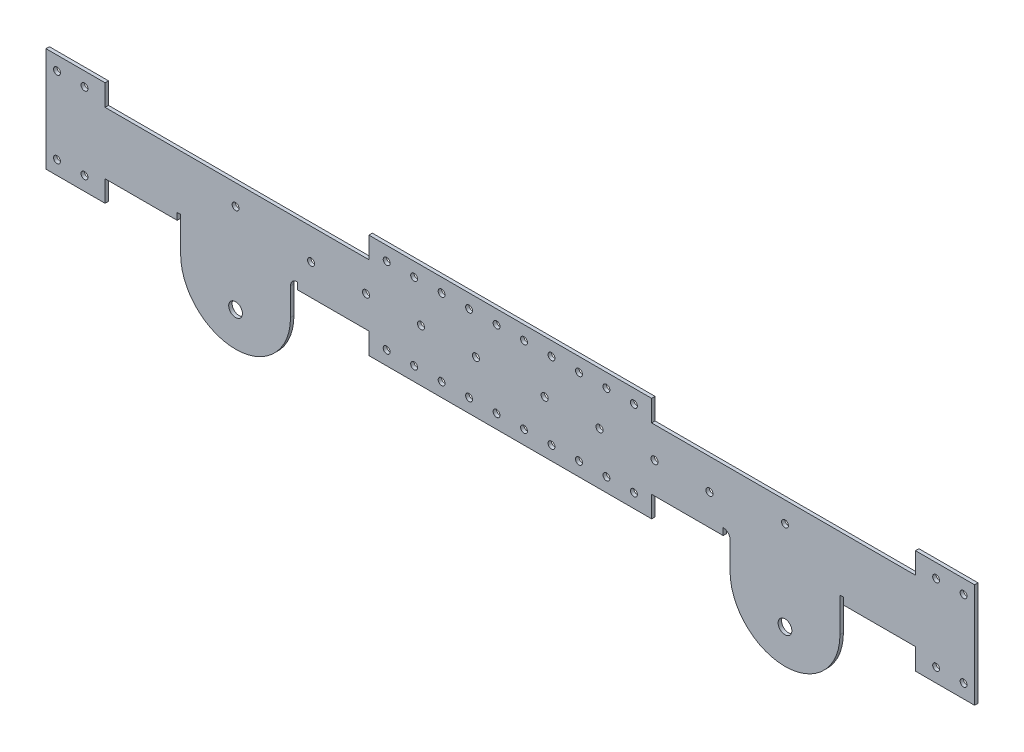
from build123d import *
from build123d.topology import SkipClean

# Parameters (mm, degrees)
SKETCH1_R            = 6.35
BOSS_EXTRUDE1_DEPTH  = 3.175
SKETCH2_W            = 596.9
SKETCH2_H            = 3.175
BOSS_EXTRUDE2_DEPTH  = 25.4
FILLET1_R            = 2.54
SKETCH3_R            = 3.2639
CUT_EXTRUDE1_DEPTH   = 25.4
SKETCH5_R            = 3.2639
CUT_EXTRUDE2_DEPTH   = 25.4
SKETCH6_W            = 31.75
SKETCH6_H            = 44.45
BOSS_EXTRUDE3_DEPTH  = 3.175
SKETCH7_W            = 31.75
SKETCH7_H            = 3.175
SKETCH7_W_2          = 381
BOSS_EXTRUDE4_DEPTH  = 25.4
FILLET2_R            = 2.54
SKETCH8_R            = 3.2639
CUT_EXTRUDE3_DEPTH   = 177.8
SKETCH9_R            = 3.2639
CUT_EXTRUDE5_DEPTH   = 432.308
BOSS_EXTRUDE6_DEPTH  = 66.675
BOSS_EXTRUDE7_START  = 66.675
BOSS_EXTRUDE7_DEPTH  = 66.675
SKETCH12_R           = 6.35
SKETCH12_R_2         = 3.2639
SKETCH12_W           = 256.6289
SKETCH12_H           = 252.715944366
CUT_EXTRUDE8_DEPTH   = 66.675
BOSS_EXTRUDE8_START  = 19.05
BOSS_EXTRUDE8_DEPTH  = 19.05
BOSS_EXTRUDE9_DEPTH  = 19.05
SKETCH16_R           = 3.2639
CUT_EXTRUDE9_DEPTH   = 133.096
SKETCH17_R           = 3.175
CUT_EXTRUDE11_DEPTH  = 5.08
SKETCH18_W           = 256.6289
SKETCH18_H           = 3.175
SKETCH18_W_2         = 838.2
BOSS_EXTRUDE10_DEPTH = 3.175
SKETCH19_W           = 107.950440108
SKETCH19_H           = 6.388661832
SKETCH19_W_2         = 107.95
SKETCH19_H_2         = 3.175
CUT_EXTRUDE12_DEPTH  = 3.175
SKETCH20_W           = 555.272296498
SKETCH20_H           = 244.428342312
SKETCH20_R           = 3.2639
SKETCH20_R_2         = 6.35
SKETCH20_R_3         = 3.175
CUT_EXTRUDE13_DEPTH  = 277.622
BOSS_EXTRUDE11_START = -3.175
SKETCH21_R           = 6.35
BOSS_EXTRUDE11_DEPTH = 3.175
SKETCH22_W           = 47.625
SKETCH22_H           = 22.225
SKETCH22_W_2         = 236.0422
BOSS_EXTRUDE12_DEPTH = 3.175
SKETCH23_W           = 47.625
SKETCH23_H           = 22.225
SKETCH23_W_2         = 236.0422
BOSS_EXTRUDE14_DEPTH = 3.175
BOSS_EXTRUDE15_DEPTH = 12.7
BOSS_EXTRUDE16_START = 12.7
BOSS_EXTRUDE16_DEPTH = 12.7
SKETCH27_R           = 3.175
CUT_EXTRUDE15_DEPTH  = 76.2
SKETCH28_W           = 22.225
SKETCH28_H           = 3.175
BOSS_EXTRUDE17_DEPTH = 12.7
SKETCH29_W           = 22.225
SKETCH29_H           = 3.175
BOSS_EXTRUDE18_DEPTH = 12.7
SKETCH30_R           = 6.321493949
BOSS_EXTRUDE19_DEPTH = 3.175
SKETCH31_R           = 6.35
CUT_EXTRUDE16_DEPTH  = 3.175
SKETCH32_W           = 28.574777667
SKETCH32_H           = 18.699670679
BOSS_EXTRUDE20_DEPTH = 3.175
CUT_EXTRUDE17_START  = -5.715
CUT_EXTRUDE17_DEPTH  = 5.715
CUT_EXTRUDE18_DEPTH  = 5.715
SKETCH35_R           = 3.175
BOSS_EXTRUDE21_DEPTH = 3.175
SKETCH36_W           = 977.185411366
SKETCH36_H           = 114.319758196
CUT_EXTRUDE19_DEPTH  = 76.2


with BuildPart() as part:
    # Sketch1 → Boss-Extrude1 (new body)
    with BuildSketch(Plane.XY):
        with BuildLine():
            Line((50.8, 0), (50.8, 25.4))
            ThreePointArc((50.8, 25.4), (52.659871939, 29.890128061), (57.15, 31.75))
            Line((57.15, 31.75), (438.15, 31.75))
            ThreePointArc((438.15, 31.75), (442.640128061, 29.890128061), (444.5, 25.4))
            Line((444.5, 25.4), (444.5, 0))
            ThreePointArc((444.5, 0), (495.3, -50.8), (546.1, 0))
            Line((546.1, 0), (546.1, 76.2))
            Line((546.1, 76.2), (-50.8, 76.2))
            Line((-50.8, 76.2), (-50.8, 0))
            ThreePointArc((-50.8, 0), (0, -50.8), (50.8, 0))
        make_face()
        Circle(SKETCH1_R, mode=Mode.SUBTRACT)
        with Locations((495.3, 0)):
            Circle(SKETCH1_R, mode=Mode.SUBTRACT)
    extrude(amount=BOSS_EXTRUDE1_DEPTH)

    # Sketch2 → Boss-Extrude2 (add)
    with BuildSketch(Plane.XY.offset(3.175)):
        with Locations((247.65, 74.6125)):
            Rectangle(SKETCH2_W, SKETCH2_H)
    extrude(amount=BOSS_EXTRUDE2_DEPTH)

    # Fillet1
    fillet1_edges = [part.edges().sort_by_distance(p)[0] for p in [
        (247.65, 73.025, 3.175),
        (247.65, 76.2, 0),
    ]]
    fillet(fillet1_edges, radius=FILLET1_R)

    # Sketch3 → Cut-Extrude1 (cut)
    with BuildSketch(Plane(origin=(0, 76.2, 0), x_dir=(1, 0, 0), z_dir=(0, 1, 0))):
        with Locations((527.05, -15.5575)):
            Circle(SKETCH3_R)
        with Locations((501.65, -15.5575)):
            Circle(SKETCH3_R)
        with Locations((476.25, -15.5575)):
            Circle(SKETCH3_R)
        with Locations((450.85, -15.5575)):
            Circle(SKETCH3_R)
        with Locations((425.45, -15.5575)):
            Circle(SKETCH3_R)
        with Locations((400.05, -15.5575)):
            Circle(SKETCH3_R)
        with Locations((374.65, -15.5575)):
            Circle(SKETCH3_R)
        with Locations((349.25, -15.5575)):
            Circle(SKETCH3_R)
        with Locations((323.85, -15.5575)):
            Circle(SKETCH3_R)
        with Locations((298.45, -15.5575)):
            Circle(SKETCH3_R)
        with Locations((273.05, -15.5575)):
            Circle(SKETCH3_R)
        with Locations((247.65, -15.5575)):
            Circle(SKETCH3_R)
        with Locations((222.25, -15.5575)):
            Circle(SKETCH3_R)
        with Locations((196.85, -15.5575)):
            Circle(SKETCH3_R)
        with Locations((171.45, -15.5575)):
            Circle(SKETCH3_R)
        with Locations((146.05, -15.5575)):
            Circle(SKETCH3_R)
        with Locations((120.65, -15.5575)):
            Circle(SKETCH3_R)
        with Locations((95.25, -15.5575)):
            Circle(SKETCH3_R)
        with Locations((69.85, -15.5575)):
            Circle(SKETCH3_R)
        with Locations((44.45, -15.5575)):
            Circle(SKETCH3_R)
        with Locations((19.05, -15.5575)):
            Circle(SKETCH3_R)
        with Locations((-6.35, -15.5575)):
            Circle(SKETCH3_R)
        with Locations((-31.75, -15.5575)):
            Circle(SKETCH3_R)
    extrude(amount=-CUT_EXTRUDE1_DEPTH, mode=Mode.SUBTRACT)

    # Sketch5 → Cut-Extrude2 (cut)
    with BuildSketch(Plane(origin=(0, 0, 0), x_dir=(-1, 0, 0), z_dir=(0, 0, -1))):
        with Locations((-425.45, 53.975)):
            Circle(SKETCH5_R)
        with Locations((-374.65, 53.975)):
            Circle(SKETCH5_R)
        with Locations((-323.85, 53.975)):
            Circle(SKETCH5_R)
        with Locations((-273.05, 53.975)):
            Circle(SKETCH5_R)
        with Locations((-222.25, 53.975)):
            Circle(SKETCH5_R)
        with Locations((-171.45, 53.975)):
            Circle(SKETCH5_R)
        with Locations((-120.65, 53.975)):
            Circle(SKETCH5_R)
        with Locations((-69.85, 53.975)):
            Circle(SKETCH5_R)
    extrude(amount=-CUT_EXTRUDE2_DEPTH, mode=Mode.SUBTRACT)

    # Sketch6 → Boss-Extrude3 (add)
    with BuildSketch(Plane.XY.offset(3.175)):
        with Locations((-66.675, 53.975)):
            Rectangle(SKETCH6_W, SKETCH6_H)
        with Locations((561.975, 53.975)):
            Rectangle(SKETCH6_W, SKETCH6_H)
    extrude(amount=-BOSS_EXTRUDE3_DEPTH)

    # Sketch7 → Boss-Extrude4 (add)
    with BuildSketch(Plane.XY.offset(3.175)):
        with Locations((-66.675, 74.6125)):
            Rectangle(SKETCH7_W, SKETCH7_H)
        with Locations((-66.675, 33.3375)):
            Rectangle(SKETCH7_W, SKETCH7_H)
        with Locations((561.975, 74.6125)):
            Rectangle(SKETCH7_W, SKETCH7_H)
        with Locations((561.975, 33.3375)):
            Rectangle(SKETCH7_W, SKETCH7_H)
        with Locations((247.65, 33.3375)):
            Rectangle(SKETCH7_W_2, SKETCH7_H)
    extrude(amount=BOSS_EXTRUDE4_DEPTH)

    # Fillet2
    fillet2_edges = [part.edges().sort_by_distance(p)[0] for p in [
        (-50.8, 15.875, 0),
        (0, -50.8, 0),
        (50.8, 12.7, 0),
        (52.659871939, 29.890128061, 0),
        (546.1, 15.875, 0),
        (495.3, -50.8, 0),
        (444.5, 12.7, 0),
        (442.640128061, 29.890128061, 0),
        (-66.675, 34.925, 3.175),
        (-66.675, 31.75, 0),
        (247.65, 31.75, 0),
        (247.65, 34.925, 3.175),
        (561.975, 34.925, 3.175),
        (561.975, 31.75, 0),
        (561.975, 76.2, 0),
        (-66.675, 76.2, 0),
    ]]
    fillet(fillet2_edges, radius=FILLET2_R)

    # Sketch8 → Cut-Extrude3 (cut)
    with BuildSketch(Plane(origin=(0, 76.2, 0), x_dir=(1, 0, 0), z_dir=(0, 1, 0))):
        with Locations((-31.75, -15.5575)):
            Circle(SKETCH8_R)
        with Locations((-57.15, -15.5575)):
            Circle(SKETCH8_R)
        with Locations((-6.35, -15.5575)):
            Circle(SKETCH8_R)
        with Locations((19.05, -15.5575)):
            Circle(SKETCH8_R)
        with Locations((44.45, -15.5575)):
            Circle(SKETCH8_R)
        with Locations((69.85, -15.5575)):
            Circle(SKETCH8_R)
        with Locations((95.25, -15.5575)):
            Circle(SKETCH8_R)
        with Locations((120.65, -15.5575)):
            Circle(SKETCH8_R)
        with Locations((146.05, -15.5575)):
            Circle(SKETCH8_R)
        with Locations((171.45, -15.5575)):
            Circle(SKETCH8_R)
        with Locations((196.85, -15.5575)):
            Circle(SKETCH8_R)
        with Locations((222.25, -15.5575)):
            Circle(SKETCH8_R)
        with Locations((247.65, -15.5575)):
            Circle(SKETCH8_R)
        with Locations((273.05, -15.5575)):
            Circle(SKETCH8_R)
        with Locations((298.45, -15.5575)):
            Circle(SKETCH8_R)
        with Locations((323.85, -15.5575)):
            Circle(SKETCH8_R)
        with Locations((349.25, -15.5575)):
            Circle(SKETCH8_R)
        with Locations((374.65, -15.5575)):
            Circle(SKETCH8_R)
        with Locations((400.05, -15.5575)):
            Circle(SKETCH8_R)
        with Locations((425.45, -15.5575)):
            Circle(SKETCH8_R)
        with Locations((450.85, -15.5575)):
            Circle(SKETCH8_R)
        with Locations((476.25, -15.5575)):
            Circle(SKETCH8_R)
        with Locations((501.65, -15.5575)):
            Circle(SKETCH8_R)
        with Locations((527.05, -15.5575)):
            Circle(SKETCH8_R)
        with Locations((552.45, -15.5575)):
            Circle(SKETCH8_R)
    extrude(amount=-CUT_EXTRUDE3_DEPTH, mode=Mode.SUBTRACT)

    # Sketch9 → Cut-Extrude5 (cut)
    with BuildSketch(Plane(origin=(0, 76.2, 0), x_dir=(1, 0, 0), z_dir=(0, 1, 0))):
        with BuildLine():
            Line((298.45, -18.8214), (298.45, -28.575))
            Line((298.45, -28.575), (746.392900795, -28.575))
            Line((746.392900795, -28.575), (746.392900795, 89.004110939))
            Line((746.392900795, 89.004110939), (298.45, 89.004110939))
            Line((298.45, 89.004110939), (298.45, -12.2936))
            ThreePointArc((298.45, -12.2936), (301.7139, -15.5575), (298.45, -18.8214))
        make_face()
        with Locations((323.85, -15.5575)):
            Circle(SKETCH9_R, mode=Mode.SUBTRACT)
        with Locations((349.25, -15.5575)):
            Circle(SKETCH9_R, mode=Mode.SUBTRACT)
        with Locations((374.65, -15.5575)):
            Circle(SKETCH9_R, mode=Mode.SUBTRACT)
        with Locations((400.05, -15.5575)):
            Circle(SKETCH9_R, mode=Mode.SUBTRACT)
        with Locations((425.45, -15.5575)):
            Circle(SKETCH9_R, mode=Mode.SUBTRACT)
        with Locations((450.85, -15.5575)):
            Circle(SKETCH9_R, mode=Mode.SUBTRACT)
        with Locations((476.25, -15.5575)):
            Circle(SKETCH9_R, mode=Mode.SUBTRACT)
        with Locations((501.65, -15.5575)):
            Circle(SKETCH9_R, mode=Mode.SUBTRACT)
        with Locations((527.05, -15.5575)):
            Circle(SKETCH9_R, mode=Mode.SUBTRACT)
        with Locations((552.45, -15.5575)):
            Circle(SKETCH9_R, mode=Mode.SUBTRACT)
    extrude(amount=-CUT_EXTRUDE5_DEPTH, mode=Mode.SUBTRACT)

    # Mirror4: part across plane


with BuildPart() as part_1:
    with SkipClean():  # the faces are left unmerged after this step: merging them gives an invalid solid
        add(part.part)
        add(part.part.mirror(Plane(origin=(298.45, -356.108, 0), x_dir=(0, 0, 1), z_dir=(1, 0, 0))))

    # Sketch10 → Boss-Extrude6 (add)
    with SkipClean():  # the faces are left unmerged after this step: merging them gives an invalid solid
        with BuildSketch(Plane.ZY.offset(82.55)):
            with BuildLine():
                Line((0, 73.66), (0, 34.29))
                ThreePointArc((0, 34.29), (0.743948776, 32.493948776), (2.54, 31.75))
                Line((2.54, 31.75), (28.575, 31.75))
                Line((28.575, 31.75), (28.575, 34.925))
                Line((28.575, 34.925), (5.715, 34.925))
                ThreePointArc((5.715, 34.925), (3.918948776, 35.668948776), (3.175, 37.465))
                Line((3.175, 37.465), (3.175, 73.025))
                Line((3.175, 73.025), (28.575, 73.025))
                Line((28.575, 73.025), (28.575, 76.2))
                Line((28.575, 76.2), (2.54, 76.2))
                ThreePointArc((2.54, 76.2), (0.743948776, 75.456051224), (0, 73.66))
            make_face()
        extrude(amount=BOSS_EXTRUDE6_DEPTH)

    # Sketch11 → Boss-Extrude7 (add)
    with SkipClean():  # the faces are left unmerged after this step: merging them gives an invalid solid
        with BuildSketch(Plane(origin=(679.45, 0, 0), x_dir=(0, 0, -1), z_dir=(1, 0, 0)).offset(BOSS_EXTRUDE7_START)):
            with BuildLine():
                Line((0, 34.29), (0, 73.66))
                ThreePointArc((0, 73.66), (-0.743948776, 75.456051224), (-2.54, 76.2))
                Line((-2.54, 76.2), (-28.575, 76.2))
                Line((-28.575, 76.2), (-28.575, 73.025))
                Line((-28.575, 73.025), (-3.175, 73.025))
                Line((-3.175, 73.025), (-3.175, 37.465))
                ThreePointArc((-3.175, 37.465), (-3.918948776, 35.668948776), (-5.715, 34.925))
                Line((-5.715, 34.925), (-28.575, 34.925))
                Line((-28.575, 34.925), (-28.575, 31.75))
                Line((-28.575, 31.75), (-2.54, 31.75))
                ThreePointArc((-2.54, 31.75), (-0.743948776, 32.493948776), (0, 34.29))
            make_face()
        extrude(amount=-BOSS_EXTRUDE7_DEPTH)

    # Sketch12 → Cut-Extrude8 (cut)
    # profile 1 of 2: a face of its own
    with SkipClean():  # the faces are left unmerged after this step: merging them gives an invalid solid
        with BuildSketch(Plane.XY.offset(3.175)):
            with BuildLine():
                Line((135.9789, 114.3), (-120.65, 114.3))
                Line((-120.65, 114.3), (-120.65, -7.986269461))
                Line((-120.65, -7.986269461), (-114.3, -7.986269461))
                Line((-114.3, -7.986269461), (-114.3, 0))
                ThreePointArc((-114.3, 0), (0, -114.3), (114.3, 0))
                Line((114.3, 0), (114.3, -15.458780647))
                Line((114.3, -15.458780647), (135.9789, -15.458780647))
                Line((135.9789, -15.458780647), (135.9789, 114.3))
            make_face()
            Circle(SKETCH12_R, mode=Mode.SUBTRACT)
            with Locations((69.85, 53.975)):
                Circle(SKETCH12_R_2, mode=Mode.SUBTRACT)
            with Locations((120.65, 53.975)):
                Circle(SKETCH12_R_2, mode=Mode.SUBTRACT)
        # profile 2 of 2: a face of its own
        with BuildSketch(Plane.XY.offset(3.175)):
            with Locations((589.23555, 8.748218221)):
                Rectangle(SKETCH12_W, SKETCH12_H)
            with Locations((596.9, 0)):
                Circle(SKETCH12_R, mode=Mode.SUBTRACT)
            with Locations((476.25, 53.975)):
                Circle(SKETCH12_R_2, mode=Mode.SUBTRACT)
            with Locations((527.05, 53.975)):
                Circle(SKETCH12_R_2, mode=Mode.SUBTRACT)
        extrude(amount=CUT_EXTRUDE8_DEPTH, mode=Mode.SUBTRACT)

    # Sketch14 → Boss-Extrude8 (add)
    with SkipClean():  # the faces are left unmerged after this step: merging them gives an invalid solid
        with BuildSketch(Plane(origin=(746.125, 0, 0), x_dir=(0, 0, -1), z_dir=(1, 0, 0)).offset(BOSS_EXTRUDE8_START)):
            with BuildLine():
                Line((0, 34.29), (0, 73.66))
                ThreePointArc((0, 73.66), (-0.743948776, 75.456051224), (-2.54, 76.2))
                Line((-2.54, 76.2), (-28.575, 76.2))
                Line((-28.575, 76.2), (-28.575, 73.025))
                Line((-28.575, 73.025), (-3.175, 73.025))
                Line((-3.175, 73.025), (-3.175, 37.465))
                ThreePointArc((-3.175, 37.465), (-3.918948776, 35.668948776), (-5.715, 34.925))
                Line((-5.715, 34.925), (-28.575, 34.925))
                Line((-28.575, 34.925), (-28.575, 31.75))
                Line((-28.575, 31.75), (-2.54, 31.75))
                ThreePointArc((-2.54, 31.75), (-0.743948776, 32.493948776), (0, 34.29))
            make_face()
        extrude(amount=-BOSS_EXTRUDE8_DEPTH)

    # Sketch15 → Boss-Extrude9 (add)
    with SkipClean():  # the faces are left unmerged after this step: merging them gives an invalid solid
        with BuildSketch(Plane.ZY.offset(149.225)):
            with BuildLine():
                Line((0, 73.66), (0, 34.29))
                ThreePointArc((0, 34.29), (0.743948776, 32.493948776), (2.54, 31.75))
                Line((2.54, 31.75), (28.575, 31.75))
                Line((28.575, 31.75), (28.575, 34.925))
                Line((28.575, 34.925), (5.715, 34.925))
                ThreePointArc((5.715, 34.925), (3.918948776, 35.668948776), (3.175, 37.465))
                Line((3.175, 37.465), (3.175, 73.025))
                Line((3.175, 73.025), (28.575, 73.025))
                Line((28.575, 73.025), (28.575, 76.2))
                Line((28.575, 76.2), (2.54, 76.2))
                ThreePointArc((2.54, 76.2), (0.743948776, 75.456051224), (0, 73.66))
            make_face()
        extrude(amount=BOSS_EXTRUDE9_DEPTH)

    # Sketch16 → Cut-Extrude9 (cut)
    with SkipClean():  # the faces are left unmerged after this step: merging them gives an invalid solid
        with BuildSketch(Plane(origin=(0, 76.2, 0), x_dir=(1, 0, 0), z_dir=(0, 1, 0))):
            with Locations((146.05, -15.5575)):
                Circle(SKETCH16_R)
            with Locations((171.45, -15.5575)):
                Circle(SKETCH16_R)
            with Locations((196.85, -15.5575)):
                Circle(SKETCH16_R)
            with Locations((222.25, -15.5575)):
                Circle(SKETCH16_R)
            with Locations((247.65, -15.5575)):
                Circle(SKETCH16_R)
            with Locations((273.05, -15.5575)):
                Circle(SKETCH16_R)
            with Locations((298.45, -15.5575)):
                Circle(SKETCH16_R)
            with Locations((323.85, -15.5575)):
                Circle(SKETCH16_R)
            with Locations((349.25, -15.5575)):
                Circle(SKETCH16_R)
            with Locations((374.65, -15.5575)):
                Circle(SKETCH16_R)
            with Locations((400.05, -15.5575)):
                Circle(SKETCH16_R)
            with Locations((425.45, -15.5575)):
                Circle(SKETCH16_R)
            with Locations((450.85, -15.5575)):
                Circle(SKETCH16_R)
            with Locations((476.25, -15.5575)):
                Circle(SKETCH16_R)
            with Locations((501.65, -15.5575)):
                Circle(SKETCH16_R)
            with Locations((527.05, -15.5575)):
                Circle(SKETCH16_R)
            with Locations((552.45, -15.5575)):
                Circle(SKETCH16_R)
            with Locations((577.85, -15.5575)):
                Circle(SKETCH16_R)
            with Locations((603.25, -15.5575)):
                Circle(SKETCH16_R)
            with Locations((628.65, -15.5575)):
                Circle(SKETCH16_R)
            with Locations((654.05, -15.5575)):
                Circle(SKETCH16_R)
            with Locations((679.45, -15.5575)):
                Circle(SKETCH16_R)
            with Locations((704.85, -15.5575)):
                Circle(SKETCH16_R)
            with Locations((730.25, -15.5575)):
                Circle(SKETCH16_R)
            with Locations((755.65, -15.5575)):
                Circle(SKETCH16_R)
            with Locations((120.65, -15.5575)):
                Circle(SKETCH16_R)
            with Locations((95.25, -15.5575)):
                Circle(SKETCH16_R)
            with Locations((69.85, -15.5575)):
                Circle(SKETCH16_R)
            with Locations((44.45, -15.5575)):
                Circle(SKETCH16_R)
            with Locations((19.05, -15.5575)):
                Circle(SKETCH16_R)
            with Locations((-6.35, -15.5575)):
                Circle(SKETCH16_R)
            with Locations((-31.75, -15.5575)):
                Circle(SKETCH16_R)
            with Locations((-57.15, -15.5575)):
                Circle(SKETCH16_R)
            with Locations((-82.55, -15.5575)):
                Circle(SKETCH16_R)
            with Locations((-107.95, -15.5575)):
                Circle(SKETCH16_R)
            with Locations((-133.35, -15.5575)):
                Circle(SKETCH16_R)
            with Locations((-158.75, -15.5575)):
                Circle(SKETCH16_R)
        extrude(amount=-CUT_EXTRUDE9_DEPTH, mode=Mode.SUBTRACT)

    # Sketch17 → Cut-Extrude11 (cut)
    with SkipClean():  # the faces are left unmerged after this step: merging them gives an invalid solid
        with BuildSketch(Plane(origin=(0, 0, 0), x_dir=(-1, 0, 0), z_dir=(0, 0, -1))):
            with Locations((0, 63.5)):
                Circle(SKETCH17_R)
            with Locations((-596.9, 63.5)):
                Circle(SKETCH17_R)
        extrude(amount=-CUT_EXTRUDE11_DEPTH, mode=Mode.SUBTRACT)

    # Sketch18 → Boss-Extrude10 (add)
    with SkipClean():  # the faces are left unmerged after this step: merging them gives an invalid solid
        with BuildSketch(Plane.XY.offset(3.175)):
            with Locations((7.66445, 74.6125)):
                Rectangle(SKETCH18_W, SKETCH18_H)
            with Locations((589.23555, 74.6125)):
                Rectangle(SKETCH18_W, SKETCH18_H)
            with Locations((298.45, 33.3375)):
                Rectangle(SKETCH18_W_2, SKETCH18_H)
        extrude(amount=BOSS_EXTRUDE10_DEPTH)

    # Sketch19 → Cut-Extrude12 (cut)
    with SkipClean():  # the faces are left unmerged after this step: merging them gives an invalid solid
        with BuildSketch(Plane.XY.offset(3.175)):
            with Locations((3.175220054, 34.944330916)):
                Rectangle(SKETCH19_W, SKETCH19_H)
            with Locations((593.725, 33.3375)):
                Rectangle(SKETCH19_W_2, SKETCH19_H_2)
        extrude(amount=CUT_EXTRUDE12_DEPTH, mode=Mode.SUBTRACT)

    # Sketch20 → Cut-Extrude13 (cut)
    with BuildSketch(Plane(origin=(0, 0, 0), x_dir=(-1, 0, 0), z_dir=(0, 0, -1))):
        with Locations((-65.263851751, 61.916295681)):
            Rectangle(SKETCH20_W, SKETCH20_H)
        with Locations((-323.85, 53.975)):
            Circle(SKETCH20_R, mode=Mode.SUBTRACT)
        with Locations((-273.05, 53.975)):
            Circle(SKETCH20_R, mode=Mode.SUBTRACT)
        with Locations((-222.25, 53.975)):
            Circle(SKETCH20_R, mode=Mode.SUBTRACT)
        with Locations((-171.45, 53.975)):
            Circle(SKETCH20_R, mode=Mode.SUBTRACT)
        with Locations((-120.65, 53.975)):
            Circle(SKETCH20_R, mode=Mode.SUBTRACT)
        with Locations((-69.85, 53.975)):
            Circle(SKETCH20_R, mode=Mode.SUBTRACT)
        Circle(SKETCH20_R_2, mode=Mode.SUBTRACT)
        with Locations((0, 63.5)):
            Circle(SKETCH20_R_3, mode=Mode.SUBTRACT)
    extrude(amount=-CUT_EXTRUDE13_DEPTH, mode=Mode.SUBTRACT)

    # Sketch21 → Boss-Extrude11 (add)
    with BuildSketch(Plane.XY.offset(3.175).offset(BOSS_EXTRUDE11_START)):
        with BuildLine():
            Line((546.1, 0), (546.1, 25.4))
            ThreePointArc((546.1, 25.4), (544.240128061, 29.890128061), (539.75, 31.75))
            Line((539.75, 31.75), (539.75, 34.925))
            Line((539.75, 34.925), (647.7, 34.925))
            Line((647.7, 34.925), (647.7, 31.75))
            Line((647.7, 31.75), (647.7, 0))
            ThreePointArc((647.7, 0), (596.9, -50.8), (546.1, 0))
        make_face()
        with Locations((596.9, 0)):
            Circle(SKETCH21_R, mode=Mode.SUBTRACT)
    extrude(amount=BOSS_EXTRUDE11_DEPTH)

    # Mirror5: part across plane


with BuildPart() as part_2:
    add(part_1.part)
    add(part_1.part.mirror(Plane(origin=(342.9, 0, 277.622), x_dir=(0, 0, 1), z_dir=(1, 0, 0))))

    # Sketch22 → Boss-Extrude12 (add)
    with BuildSketch(Plane(origin=(0, 76.2, 0), x_dir=(1, 0, 0), z_dir=(0, 1, 0))):
        with Locations((741.3625, -17.4625)):
            Rectangle(SKETCH22_W, SKETCH22_H)
        with Locations((342.9, -17.4625)):
            Rectangle(SKETCH22_W_2, SKETCH22_H)
        with Locations((-55.5625, -17.4625)):
            Rectangle(SKETCH22_W, SKETCH22_H)
    extrude(amount=-BOSS_EXTRUDE12_DEPTH)

    # Sketch23 → Boss-Extrude14 (add)
    with BuildSketch(Plane.XZ.offset(-31.75)):
        with Locations((-55.5625, 17.4625)):
            Rectangle(SKETCH23_W, SKETCH23_H)
        with Locations((342.9, 17.4625)):
            Rectangle(SKETCH23_W_2, SKETCH23_H)
        with Locations((741.3625, 17.4625)):
            Rectangle(SKETCH23_W, SKETCH23_H)
    extrude(amount=-BOSS_EXTRUDE14_DEPTH)

    # Sketch25 → Boss-Extrude15 (add)
    with BuildSketch(Plane.ZY.offset(79.375)):
        with BuildLine():
            Line((2.54, 31.75), (28.575, 31.75))
            Line((28.575, 31.75), (28.575, 34.925))
            Line((28.575, 34.925), (5.715, 34.925))
            ThreePointArc((5.715, 34.925), (3.918948776, 35.668948776), (3.175, 37.465))
            Line((3.175, 37.465), (3.175, 73.025))
            Line((3.175, 73.025), (28.575, 73.025))
            Line((28.575, 73.025), (28.575, 76.2))
            Line((28.575, 76.2), (2.54, 76.2))
            ThreePointArc((2.54, 76.2), (0.743948776, 75.456051224), (0, 73.66))
            Line((0, 73.66), (0, 34.29))
            ThreePointArc((0, 34.29), (0.743948776, 32.493948776), (2.54, 31.75))
        make_face()
    extrude(amount=BOSS_EXTRUDE15_DEPTH)

    # Sketch26 → Boss-Extrude16 (add)
    with BuildSketch(Plane(origin=(765.175, 0, 0), x_dir=(0, 0, -1), z_dir=(1, 0, 0)).offset(BOSS_EXTRUDE16_START)):
        with BuildLine():
            Line((-5.715, 34.925), (-28.575, 34.925))
            Line((-28.575, 34.925), (-28.575, 31.75))
            Line((-28.575, 31.75), (-2.54, 31.75))
            ThreePointArc((-2.54, 31.75), (-0.743948776, 32.493948776), (0, 34.29))
            Line((0, 34.29), (0, 73.66))
            ThreePointArc((0, 73.66), (-0.743948776, 75.456051224), (-2.54, 76.2))
            Line((-2.54, 76.2), (-28.575, 76.2))
            Line((-28.575, 76.2), (-28.575, 73.025))
            Line((-28.575, 73.025), (-3.175, 73.025))
            Line((-3.175, 73.025), (-3.175, 37.465))
            ThreePointArc((-3.175, 37.465), (-3.918948776, 35.668948776), (-5.715, 34.925))
        make_face()
    extrude(amount=-BOSS_EXTRUDE16_DEPTH)

    # Sketch27 → Cut-Extrude15 (cut)
    with BuildSketch(Plane(origin=(0, 76.2, 0), x_dir=(1, 0, 0), z_dir=(0, 1, 0))):
        with Locations((762, -15.788044632)):
            Circle(SKETCH27_R)
        with Locations((736.6, -15.788044632)):
            Circle(SKETCH27_R)
        with Locations((711.2, -15.788044632)):
            Circle(SKETCH27_R)
        with Locations((685.8, -15.788044632)):
            Circle(SKETCH27_R)
        with Locations((660.4, -15.788044632)):
            Circle(SKETCH27_R)
        with Locations((635, -15.788044632)):
            Circle(SKETCH27_R)
        with Locations((609.6, -15.788044632)):
            Circle(SKETCH27_R)
        with Locations((584.2, -15.788044632)):
            Circle(SKETCH27_R)
        with Locations((558.8, -15.788044632)):
            Circle(SKETCH27_R)
        with Locations((533.4, -15.788044632)):
            Circle(SKETCH27_R)
        with Locations((508, -15.788044632)):
            Circle(SKETCH27_R)
        with Locations((482.6, -15.788044632)):
            Circle(SKETCH27_R)
        with Locations((457.2, -15.788044632)):
            Circle(SKETCH27_R)
        with Locations((431.8, -15.788044632)):
            Circle(SKETCH27_R)
        with Locations((406.4, -15.788044632)):
            Circle(SKETCH27_R)
        with Locations((381, -15.788044632)):
            Circle(SKETCH27_R)
        with Locations((355.6, -15.788044632)):
            Circle(SKETCH27_R)
        with Locations((330.2, -15.788044632)):
            Circle(SKETCH27_R)
        with Locations((304.8, -15.788044632)):
            Circle(SKETCH27_R)
        with Locations((279.4, -15.788044632)):
            Circle(SKETCH27_R)
        with Locations((254, -15.788044632)):
            Circle(SKETCH27_R)
        with Locations((228.6, -15.788044632)):
            Circle(SKETCH27_R)
        with Locations((203.2, -15.788044632)):
            Circle(SKETCH27_R)
        with Locations((177.8, -15.788044632)):
            Circle(SKETCH27_R)
        with Locations((152.4, -15.788044632)):
            Circle(SKETCH27_R)
        with Locations((127, -15.788044632)):
            Circle(SKETCH27_R)
        with Locations((101.6, -15.788044632)):
            Circle(SKETCH27_R)
        with Locations((76.2, -15.788044632)):
            Circle(SKETCH27_R)
        with Locations((50.8, -15.788044632)):
            Circle(SKETCH27_R)
        with Locations((25.4, -15.788044632)):
            Circle(SKETCH27_R)
        with Locations((0, -15.788044632)):
            Circle(SKETCH27_R)
        with Locations((-25.4, -15.788044632)):
            Circle(SKETCH27_R)
        with Locations((-50.8, -15.788044632)):
            Circle(SKETCH27_R)
        with Locations((-76.2, -15.788044632)):
            Circle(SKETCH27_R)
    extrude(amount=-CUT_EXTRUDE15_DEPTH, mode=Mode.SUBTRACT)

    # Sketch28 → Boss-Extrude17 (add)
    with BuildSketch(Plane.ZY.offset(-224.8789)):
        with Locations((17.4625, 74.6125)):
            Rectangle(SKETCH28_W, SKETCH28_H)
        with Locations((17.4625, 33.3375)):
            Rectangle(SKETCH28_W, SKETCH28_H)
    extrude(amount=BOSS_EXTRUDE17_DEPTH)

    # Sketch29 → Boss-Extrude18 (add)
    with BuildSketch(Plane(origin=(460.9211, 0, 0), x_dir=(0, 0, -1), z_dir=(1, 0, 0))):
        with Locations((-17.4625, 74.6125)):
            Rectangle(SKETCH29_W, SKETCH29_H)
        with Locations((-17.4625, 33.3375)):
            Rectangle(SKETCH29_W, SKETCH29_H)
    extrude(amount=BOSS_EXTRUDE18_DEPTH)

    # Sketch30 → Boss-Extrude19 (add)
    with BuildSketch(Plane.XY.offset(3.175)):
        with Locations((87.64816817, -19.05)):
            Circle(SKETCH30_R)
        Polygon((71.867948908, 15.024467729), (76.689488805, -7.576500536), (114.056423003, -16.014195355), (104.111996966, 17.133891434), align=None)
    extrude(amount=-BOSS_EXTRUDE19_DEPTH)

    # Sketch31 → Cut-Extrude16 (cut)
    with BuildSketch(Plane.XY.offset(3.175)):
        with Locations((88.9, -19.05)):
            Circle(SKETCH31_R)
        with Locations((596.9, -19.05)):
            Circle(SKETCH31_R)
    extrude(amount=-CUT_EXTRUDE16_DEPTH, mode=Mode.SUBTRACT)

    # Sketch32 → Boss-Extrude20 (add)
    with BuildSketch(Plane.XY.offset(3.175)):
        with Locations((601.058442049, 1.748623875)):
            Rectangle(SKETCH32_W, SKETCH32_H)
    extrude(amount=-BOSS_EXTRUDE20_DEPTH)

    # Sketch33 → Cut-Extrude17 (cut)
    with BuildSketch(Plane.ZY.offset(92.075).offset(CUT_EXTRUDE17_START)):
        with BuildLine():
            Line((2.54, 31.75), (28.575, 31.75))
            Line((28.575, 31.75), (28.575, 34.925))
            Line((28.575, 34.925), (5.715, 34.925))
            ThreePointArc((5.715, 34.925), (3.918948776, 35.668948776), (3.175, 37.465))
            Line((3.175, 37.465), (3.175, 73.025))
            Line((3.175, 73.025), (28.575, 73.025))
            Line((28.575, 73.025), (28.575, 76.2))
            Line((28.575, 76.2), (2.54, 76.2))
            ThreePointArc((2.54, 76.2), (0.743948776, 75.456051224), (0, 73.66))
            Line((0, 73.66), (0, 34.29))
            ThreePointArc((0, 34.29), (0.743948776, 32.493948776), (2.54, 31.75))
        make_face()
    extrude(amount=CUT_EXTRUDE17_DEPTH, mode=Mode.SUBTRACT)

    # Sketch34 → Cut-Extrude18 (cut)
    with BuildSketch(Plane(origin=(777.875, 0, 0), x_dir=(0, 0, -1), z_dir=(1, 0, 0))):
        with BuildLine():
            Line((-5.715, 34.925), (-28.575, 34.925))
            Line((-28.575, 34.925), (-28.575, 31.75))
            Line((-28.575, 31.75), (-2.54, 31.75))
            ThreePointArc((-2.54, 31.75), (-0.743948776, 32.493948776), (0, 34.29))
            Line((0, 34.29), (0, 73.66))
            ThreePointArc((0, 73.66), (-0.743948776, 75.456051224), (-2.54, 76.2))
            Line((-2.54, 76.2), (-28.575, 76.2))
            Line((-28.575, 76.2), (-28.575, 73.025))
            Line((-28.575, 73.025), (-3.175, 73.025))
            Line((-3.175, 73.025), (-3.175, 37.465))
            ThreePointArc((-3.175, 37.465), (-3.918948776, 35.668948776), (-5.715, 34.925))
        make_face()
    extrude(amount=-CUT_EXTRUDE18_DEPTH, mode=Mode.SUBTRACT)

    # Sketch35 → Boss-Extrude21 (add)
    # profile 1 of 4: a face of its own
    with BuildSketch(Plane.XY.offset(3.175)):
        Polygon((772.16, 34.925), (650.875, 34.925), (650.875, 25.4), (717.55, 25.4), (717.55, 5.715), (772.16, 5.715), align=None)
        with Locations((736.6, 18.501868)):
            Circle(SKETCH35_R, mode=Mode.SUBTRACT)
        with Locations((762, 18.501868)):
            Circle(SKETCH35_R, mode=Mode.SUBTRACT)
    # profile 2 of 4: a face of its own
    with BuildSketch(Plane.XY.offset(3.175)):
        Polygon((-86.36, 73.025), (772.16, 73.025), (772.16, 102.235), (717.55, 102.235), (717.55, 82.55), (473.6211, 82.55), (473.6211, 102.235), (212.1789, 102.235), (212.1789, 82.55), (-31.75, 82.55), (-31.75, 102.235), (-86.36, 102.235), align=None)
        with Locations((-76.2, 89.448132)):
            Circle(SKETCH35_R, mode=Mode.SUBTRACT)
        with Locations((-50.8, 89.448132)):
            Circle(SKETCH35_R, mode=Mode.SUBTRACT)
        with Locations((736.6, 89.448132)):
            Circle(SKETCH35_R, mode=Mode.SUBTRACT)
        with Locations((762, 89.448132)):
            Circle(SKETCH35_R, mode=Mode.SUBTRACT)
        with Locations((457.2, 89.448132)):
            Circle(SKETCH35_R, mode=Mode.SUBTRACT)
        with Locations((228.6, 89.448132)):
            Circle(SKETCH35_R, mode=Mode.SUBTRACT)
        with Locations((254, 89.448132)):
            Circle(SKETCH35_R, mode=Mode.SUBTRACT)
        with Locations((279.4, 89.448132)):
            Circle(SKETCH35_R, mode=Mode.SUBTRACT)
        with Locations((304.8, 89.448132)):
            Circle(SKETCH35_R, mode=Mode.SUBTRACT)
        with Locations((330.2, 89.448132)):
            Circle(SKETCH35_R, mode=Mode.SUBTRACT)
        with Locations((355.6, 89.448132)):
            Circle(SKETCH35_R, mode=Mode.SUBTRACT)
        with Locations((381, 89.448132)):
            Circle(SKETCH35_R, mode=Mode.SUBTRACT)
        with Locations((406.4, 89.448132)):
            Circle(SKETCH35_R, mode=Mode.SUBTRACT)
        with Locations((431.8, 89.448132)):
            Circle(SKETCH35_R, mode=Mode.SUBTRACT)
    # profile 3 of 4: a face of its own
    with BuildSketch(Plane.XY.offset(3.175)):
        Polygon((539.75, 25.4), (539.75, 34.925), (146.05, 34.925), (146.05, 25.4), (212.1789, 25.4), (212.1789, 5.715), (473.6211, 5.715), (473.6211, 25.4), align=None)
        with Locations((228.6, 18.501868)):
            Circle(SKETCH35_R, mode=Mode.SUBTRACT)
        with Locations((254, 18.501868)):
            Circle(SKETCH35_R, mode=Mode.SUBTRACT)
        with Locations((279.4, 18.501868)):
            Circle(SKETCH35_R, mode=Mode.SUBTRACT)
        with Locations((304.8, 18.501868)):
            Circle(SKETCH35_R, mode=Mode.SUBTRACT)
        with Locations((330.2, 18.501868)):
            Circle(SKETCH35_R, mode=Mode.SUBTRACT)
        with Locations((355.6, 18.501868)):
            Circle(SKETCH35_R, mode=Mode.SUBTRACT)
        with Locations((381, 18.501868)):
            Circle(SKETCH35_R, mode=Mode.SUBTRACT)
        with Locations((406.4, 18.501868)):
            Circle(SKETCH35_R, mode=Mode.SUBTRACT)
        with Locations((431.8, 18.501868)):
            Circle(SKETCH35_R, mode=Mode.SUBTRACT)
        with Locations((457.2, 18.501868)):
            Circle(SKETCH35_R, mode=Mode.SUBTRACT)
    # profile 4 of 4: a face of its own
    with BuildSketch(Plane.XY.offset(3.175)):
        Polygon((-31.75, 37.465), (-86.36, 37.465), (-86.36, 5.715), (-31.75, 5.715), (-31.75, 25.4), (34.925, 25.4), (34.925, 34.925), (-31.75, 34.925), align=None)
        with Locations((-76.2, 18.501868)):
            Circle(SKETCH35_R, mode=Mode.SUBTRACT)
        with Locations((-50.8, 18.501868)):
            Circle(SKETCH35_R, mode=Mode.SUBTRACT)
    extrude(amount=-BOSS_EXTRUDE21_DEPTH)

    # Sketch36 → Cut-Extrude19 (cut)
    with BuildSketch(Plane.XY.offset(3.175)):
        with Locations((368.293928835, 49.427923141)):
            Rectangle(SKETCH36_W, SKETCH36_H)
    extrude(amount=CUT_EXTRUDE19_DEPTH, mode=Mode.SUBTRACT)


solid = part_2.part
